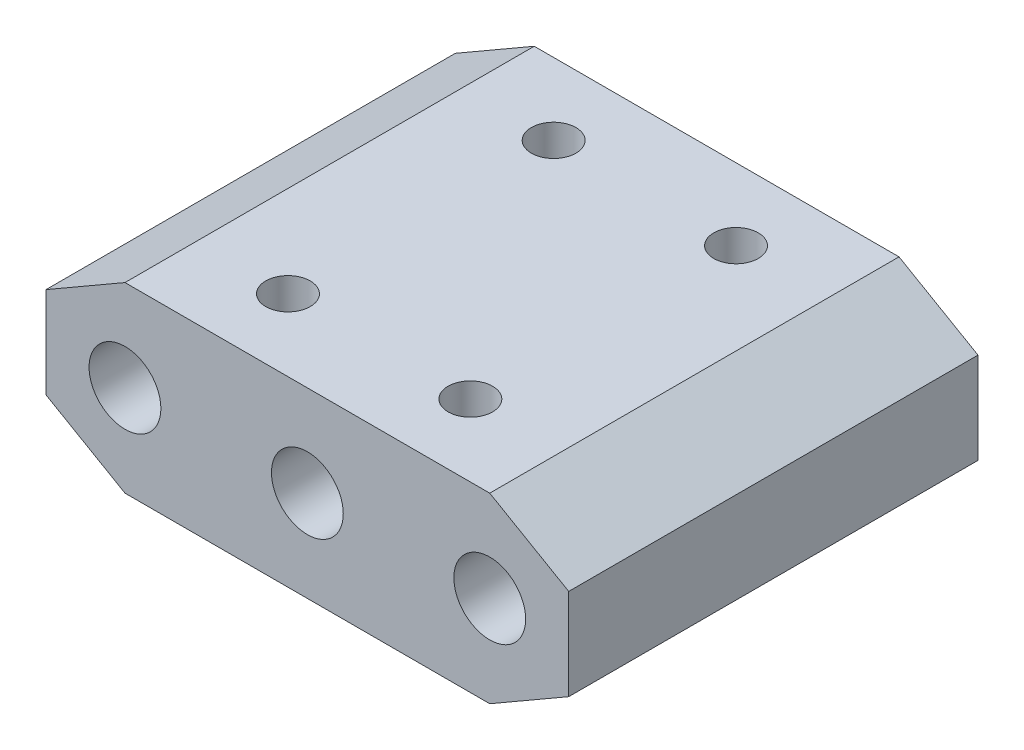
from build123d import *

# Parameters (mm, degrees)
BOSS_EXTRUDE1_DEPTH   = 28.5
M6_TAPPED_HOLE1_D     = 5
M6_TAPPED_HOLE1_DEPTH = 6
M6_TAPPED_HOLE1_TIP   = 1.502151548
M6_TAPPED_HOLE2_D     = 5
M6_TAPPED_HOLE2_DEPTH = 8
M6_TAPPED_HOLE2_TIP   = 1.502151548
SKETCH6_R             = 2.5
CUT_EXTRUDE2_DEPTH    = 29.5
SKETCH5_R             = 1.55
CUT_EXTRUDE1_DEPTH    = 13.7


with BuildPart() as part:
    # Sketch1 → Boss-Extrude1 (new body)
    with BuildSketch(Plane.XY):
        Polygon((11.849261314, 3.175), (6.35, 0), (31.75, 0), (26.250738686, 3.175), (26.250738686, 9.525), (31.75, 12.7), (6.35, 12.7), (11.849261314, 9.525), align=None)
        Polygon((0.850738686, 9.525), (0.850738686, 3.175), (6.35, 0), (11.849261314, 3.175), (11.849261314, 9.525), (6.35, 12.7), align=None)
        Polygon((26.250738686, 9.525), (26.250738686, 3.175), (31.75, 0), (37.249261314, 3.175), (37.249261314, 9.525), (31.75, 12.7), align=None)
    extrude(amount=-BOSS_EXTRUDE1_DEPTH)

    # M6 Tapped Hole1
    with Locations(Plane.XY):
        with Locations((19.05, 6.35), (31.75, 6.35), (6.35, 6.35)):
            Hole(M6_TAPPED_HOLE1_D / 2, depth=M6_TAPPED_HOLE1_DEPTH)
            with Locations((0, 0, -(M6_TAPPED_HOLE1_DEPTH + M6_TAPPED_HOLE1_TIP / 2))):  # 118° drill point
                Cone(0, M6_TAPPED_HOLE1_D / 2, M6_TAPPED_HOLE1_TIP, mode=Mode.SUBTRACT)

    # M6 Tapped Hole2
    with Locations(Plane(origin=(0, 0, -28.5), x_dir=(-1, 0, 0), z_dir=(0, 0, -1))):
        with Locations((-31.75, 6.35), (-19.05, 6.35), (-6.35, 6.35)):
            Hole(M6_TAPPED_HOLE2_D / 2, depth=M6_TAPPED_HOLE2_DEPTH)
            with Locations((0, 0, -(M6_TAPPED_HOLE2_DEPTH + M6_TAPPED_HOLE2_TIP / 2))):  # 118° drill point
                Cone(0, M6_TAPPED_HOLE2_D / 2, M6_TAPPED_HOLE2_TIP, mode=Mode.SUBTRACT)

    # Sketch6 → Cut-Extrude2 (cut, through all)
    with BuildSketch(Plane.XY):
        with Locations((6.35, 6.35)):
            Circle(SKETCH6_R)
        with Locations((19.05, 6.35)):
            Circle(SKETCH6_R)
        with Locations((31.75, 6.35)):
            Circle(SKETCH6_R)
    extrude(amount=-CUT_EXTRUDE2_DEPTH, mode=Mode.SUBTRACT)

    # Sketch5 → Cut-Extrude1 (cut, through all)
    with BuildSketch(Plane(origin=(0, 12.7, 0), x_dir=(1, 0, 0), z_dir=(0, 1, 0))):
        with Locations((12.7, 23.5)):
            Circle(SKETCH5_R)
        with Locations((25.4, 23.5)):
            Circle(SKETCH5_R)
        with Locations((25.4, 5)):
            Circle(SKETCH5_R)
        with Locations((12.7, 5)):
            Circle(SKETCH5_R)
    extrude(amount=-CUT_EXTRUDE1_DEPTH, mode=Mode.SUBTRACT)


solid = part.part
